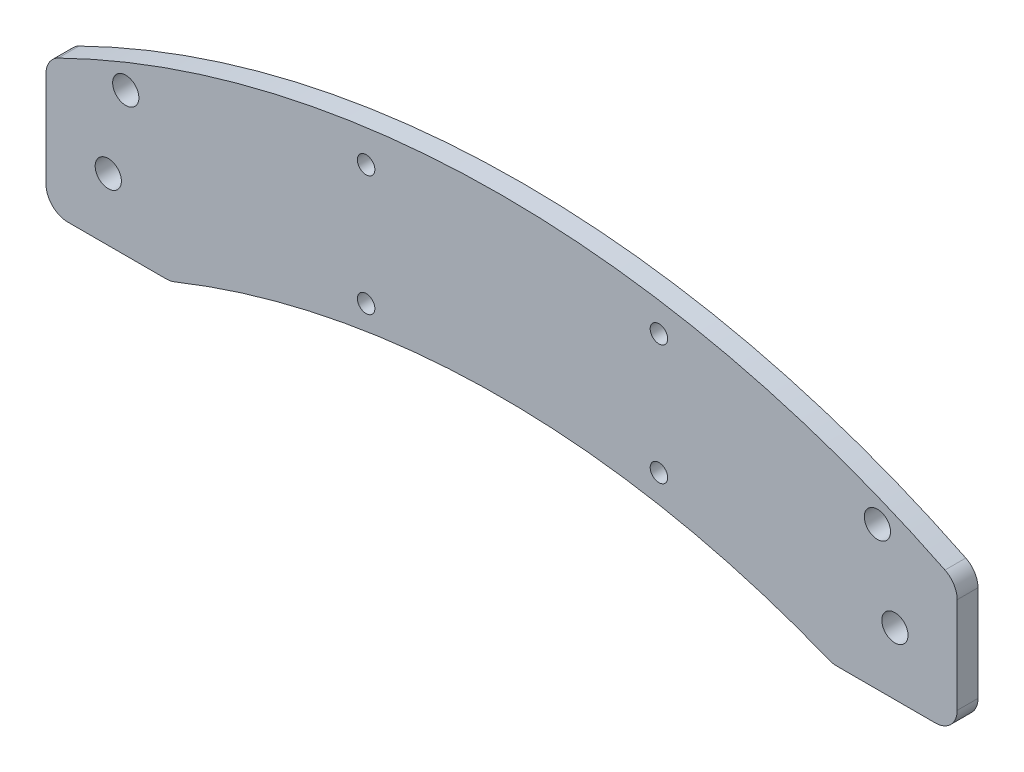
from build123d import *

# Parameters (mm, degrees)
SKETCH1_R           = 2
SKETCH1_R_2         = 3
BOSS_EXTRUDE1_DEPTH = 4.7625
SKETCH4_W           = 20
SKETCH4_H           = 20
CUT_EXTRUDE2_DEPTH  = 0.01


with BuildPart() as part:
    # Sketch1 → Boss-Extrude1 (new body)
    with BuildSketch(Plane.XY):
        with BuildLine():
            Line((-14.25, -9.25), (-14.25, 12.676812237))
            ThreePointArc((-14.25, 12.676812237), (-13.494277193, 15.319937491), (-11.455555556, 17.164074731))
            ThreePointArc((-11.455555556, 17.164074731), (90, 40.75), (191.455555556, 17.164074731))
            ThreePointArc((191.455555556, 17.164074731), (193.494277193, 15.319937491), (194.25, 12.676812237))
            Line((194.25, 12.676812237), (194.25, -9.25))
            ThreePointArc((194.25, -9.25), (192.785533906, -12.785533906), (189.25, -14.25))
            Line((189.25, -14.25), (166.727208071, -14.25))
            ThreePointArc((166.727208071, -14.25), (165.774029952, -14.158304338), (164.855812752, -13.886580589))
            ThreePointArc((164.855812752, -13.886580589), (90, 0.65019584), (15.144187248, -13.886580589))
            ThreePointArc((15.144187248, -13.886580589), (14.225970048, -14.158304338), (13.272791929, -14.25))
            Line((13.272791929, -14.25), (-9.25, -14.25))
            ThreePointArc((-9.25, -14.25), (-12.785533906, -12.785533906), (-14.25, -9.25))
        make_face()
        with Locations((59, 31.25)):
            Circle(SKETCH1_R, mode=Mode.SUBTRACT)
        with Locations((59, 3.75)):
            Circle(SKETCH1_R, mode=Mode.SUBTRACT)
        with Locations((126, 31.25)):
            Circle(SKETCH1_R, mode=Mode.SUBTRACT)
        with Locations((126, 3.75)):
            Circle(SKETCH1_R, mode=Mode.SUBTRACT)
        with Locations((180, 0)):
            Circle(SKETCH1_R_2, mode=Mode.SUBTRACT)
        Circle(SKETCH1_R_2, mode=Mode.SUBTRACT)
        with Locations((4, 18.5)):
            Circle(SKETCH1_R_2, mode=Mode.SUBTRACT)
        with Locations((176, 18.5)):
            Circle(SKETCH1_R_2, mode=Mode.SUBTRACT)
    extrude(amount=BOSS_EXTRUDE1_DEPTH)

    # Sketch4 → Cut-Extrude2 (cut)
    with BuildSketch(Plane.XY):
        Rectangle(SKETCH4_W, SKETCH4_H)
        with Locations((180, 0)):
            Rectangle(SKETCH4_W, SKETCH4_H)
    extrude(amount=CUT_EXTRUDE2_DEPTH, mode=Mode.SUBTRACT)


solid = part.part
